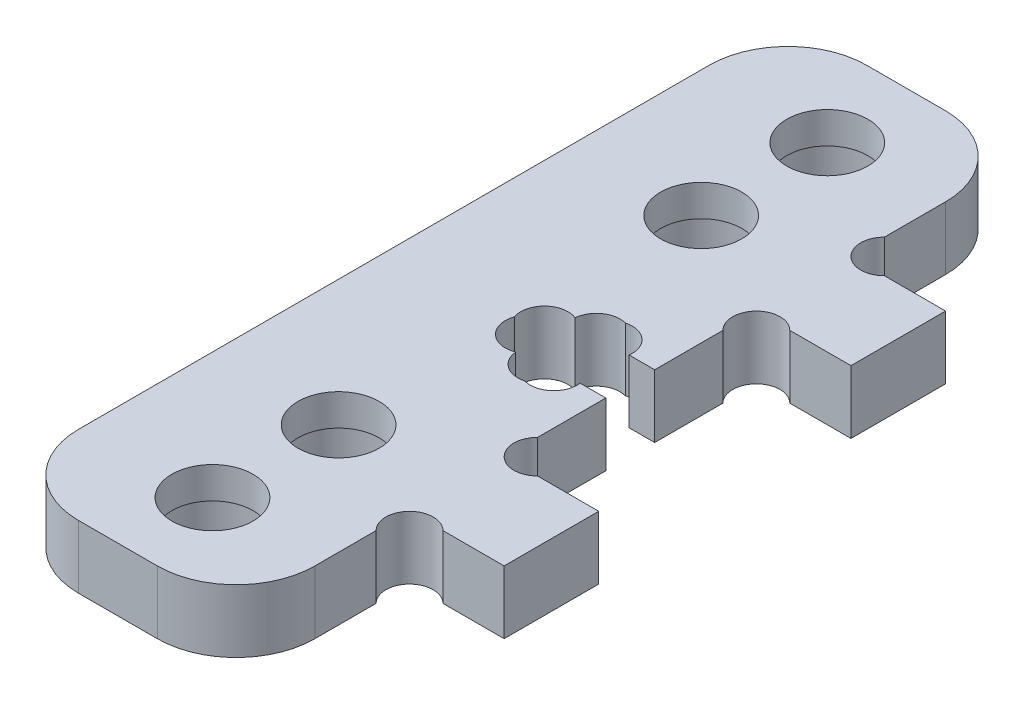
from build123d import *

# Parameters (mm, degrees)
SALIENTE_EXTRUIR1_DEPTH = 4
CORTAR_EXTRUIR4_DEPTH   = 5
CROQUIS10_R             = 1.5
CORTAR_EXTRUIR5_DEPTH   = 5
CROQUIS12_R             = 2.575
CORTAR_EXTRUIR6_DEPTH   = 5
CROQUIS13_R             = 3
CORTAR_EXTRUIR7_DEPTH   = 2


with BuildPart() as part:
    # Croquis1 → Saliente-Extruir1 (new body)
    with BuildSketch(Plane(origin=(0, 0, 0), x_dir=(1, 0, 0), z_dir=(0, 1, 0))):
        with BuildLine():
            Line((-2.5, -25), (2.5, -25))
            ThreePointArc((2.5, -25), (6.035533906, -23.535533906), (7.5, -20))
            Line((7.5, -20), (7.5, -14))
            Line((7.5, -14), (13.5, -14))
            Line((13.5, -14), (13.5, -8))
            Line((13.5, -8), (7.5, -8))
            Line((7.5, -8), (7.5, -1.55))
            Line((7.5, -1.55), (5.45, -1.55))
            Line((5.45, -1.55), (5.45, -2.8))
            Line((5.45, -2.8), (2.55, -2.8))
            Line((2.55, -2.8), (2.55, -1.55))
            Line((2.55, -1.55), (0.5, -1.55))
            Line((0.5, -1.55), (0.5, 1.55))
            Line((0.5, 1.55), (2.55, 1.55))
            Line((2.55, 1.55), (2.55, 2.8))
            Line((2.55, 2.8), (5.45, 2.8))
            Line((5.45, 2.8), (5.45, 1.55))
            Line((5.45, 1.55), (7.5, 1.55))
            Line((7.5, 1.55), (7.5, 8))
            Line((7.5, 8), (13.5, 8))
            Line((13.5, 8), (13.5, 14))
            Line((13.5, 14), (7.5, 14))
            Line((7.5, 14), (7.5, 20))
            ThreePointArc((7.5, 20), (6.035533906, 23.535533906), (2.5, 25))
            Line((2.5, 25), (-2.5, 25))
            ThreePointArc((-2.5, 25), (-6.035533906, 23.535533906), (-7.5, 20))
            Line((-7.5, 20), (-7.5, -20))
            ThreePointArc((-7.5, -20), (-6.035533906, -23.535533906), (-2.5, -25))
        make_face()
    extrude(amount=SALIENTE_EXTRUIR1_DEPTH)

    # Croquis7 → Cortar-Extruir4 (cut, through all)
    with BuildSketch(Plane(origin=(0, 4, 0), x_dir=(1, 0, 0), z_dir=(0, 1, 0))):
        with BuildLine():
            Line((5.877341989, 1.55), (7.5, 1.55))
            Line((7.5, 1.55), (7.5, -1.55))
            Line((7.5, -1.55), (5.877341989, -1.55))
            ThreePointArc((5.877341989, -1.55), (5.375478098, -2.869619136), (4, -3.187930349))
            ThreePointArc((4, -3.187930349), (2.755747615, -2.971867524), (2.117475162, -1.882163243))
            ThreePointArc((2.117475162, -1.882163243), (0.52576038, -1.575149398), (0.14272275, 0))
            ThreePointArc((0.14272275, 0), (0.52576038, 1.575149398), (2.117475162, 1.882163243))
            ThreePointArc((2.117475162, 1.882163243), (2.755747615, 2.971867524), (4, 3.187930349))
            ThreePointArc((4, 3.187930349), (5.375478098, 2.869619136), (5.877341989, 1.55))
        make_face()
    extrude(amount=-CORTAR_EXTRUIR4_DEPTH, mode=Mode.SUBTRACT)

    # Croquis10 → Cortar-Extruir5 (cut, through all)
    with BuildSketch(Plane(origin=(0, 4, 0), x_dir=(1, 0, 0), z_dir=(0, 1, 0))):
        with Locations((8.560660172, 15.060660172)):
            Circle(CROQUIS10_R)
        with Locations((8.560660172, 6.939339828)):
            Circle(CROQUIS10_R)
        with Locations((8.560660172, -15.060660172)):
            Circle(CROQUIS10_R)
        with Locations((8.560660172, -6.939339828)):
            Circle(CROQUIS10_R)
    extrude(amount=-CORTAR_EXTRUIR5_DEPTH, mode=Mode.SUBTRACT)

    # Croquis12 → Cortar-Extruir6 (cut, through all)
    with BuildSketch(Plane.XZ):
        with Locations((0.5, -11.5)):
            Circle(CROQUIS12_R)
        with Locations((0.5, -19.5)):
            Circle(CROQUIS12_R)
    cortar_extruir6 = extrude(amount=-CORTAR_EXTRUIR6_DEPTH, mode=Mode.SUBTRACT)

    # Croquis13 → Cortar-Extruir7 (cut)
    with BuildSketch(Plane.XZ):
        with Locations((0.5, -11.5)):
            Circle(CROQUIS13_R)
        with Locations((0.5, -19.5)):
            Circle(CROQUIS13_R)
    cortar_extruir7 = extrude(amount=-CORTAR_EXTRUIR7_DEPTH, mode=Mode.SUBTRACT)

    # Simetría1: Cortar-Extruir6, Cortar-Extruir7 across plane
    add(cortar_extruir6.mirror(Plane.XY), mode=Mode.SUBTRACT)
    add(cortar_extruir7.mirror(Plane.XY), mode=Mode.SUBTRACT)


solid = part.part
